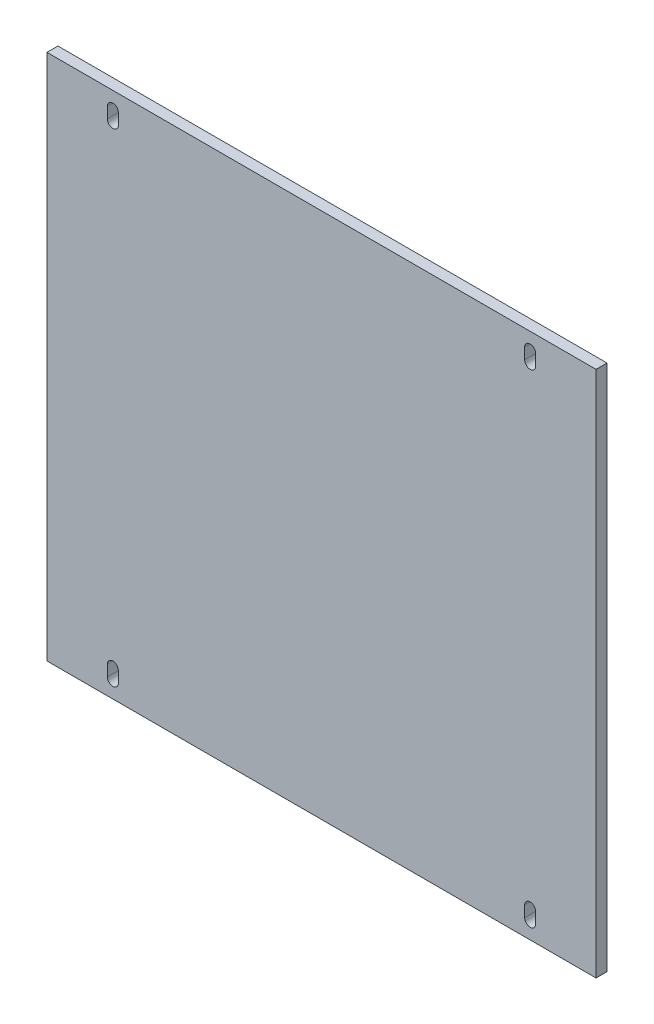
from build123d import *

# Parameters (mm, degrees)
ESQUISSE1_W                     = 250
ESQUISSE1_H                     = 240
BOSS_EXTRU_1_DEPTH              = 5
ENL_V_MAT_EXTRU_1_DEPTH         = 5
R_P_TITION_LIN_AIRE1_COUNT      = 2
R_P_TITION_LIN_AIRE1_PITCH      = 220
R_P_TITION_LIN_AIRE1_COUNT_DIR2 = 2
R_P_TITION_LIN_AIRE1_PITCH_DIR2 = 190


with BuildPart() as part:
    # Esquisse1 → Boss.-Extru.1 (new body)
    with BuildSketch(Plane.XY):
        with Locations((125, 120)):
            Rectangle(ESQUISSE1_W, ESQUISSE1_H)
    extrude(amount=BOSS_EXTRU_1_DEPTH)

    # Esquisse2 → Enlèv. mat.-Extru.1 (cut)
    with BuildSketch(Plane.XY):
        with BuildLine():
            Line((27.5, 7.5), (27.5, 12.5))
            ThreePointArc((27.5, 12.5), (30, 15), (32.5, 12.5))
            Line((32.5, 12.5), (32.5, 7.5))
            ThreePointArc((32.5, 7.5), (30, 5), (27.5, 7.5))
        make_face()
    enl_v_mat_extru_1 = extrude(amount=ENL_V_MAT_EXTRU_1_DEPTH, mode=Mode.SUBTRACT)

    # Répétition linéaire1: Enl_v. mat.-Extru.1 2 × 2
    with Locations(*[(j * R_P_TITION_LIN_AIRE1_PITCH_DIR2, i * R_P_TITION_LIN_AIRE1_PITCH, 0) for i in range(R_P_TITION_LIN_AIRE1_COUNT) for j in range(R_P_TITION_LIN_AIRE1_COUNT_DIR2) if (i, j) != (0, 0)]):
        add(enl_v_mat_extru_1, mode=Mode.SUBTRACT)


solid = part.part
